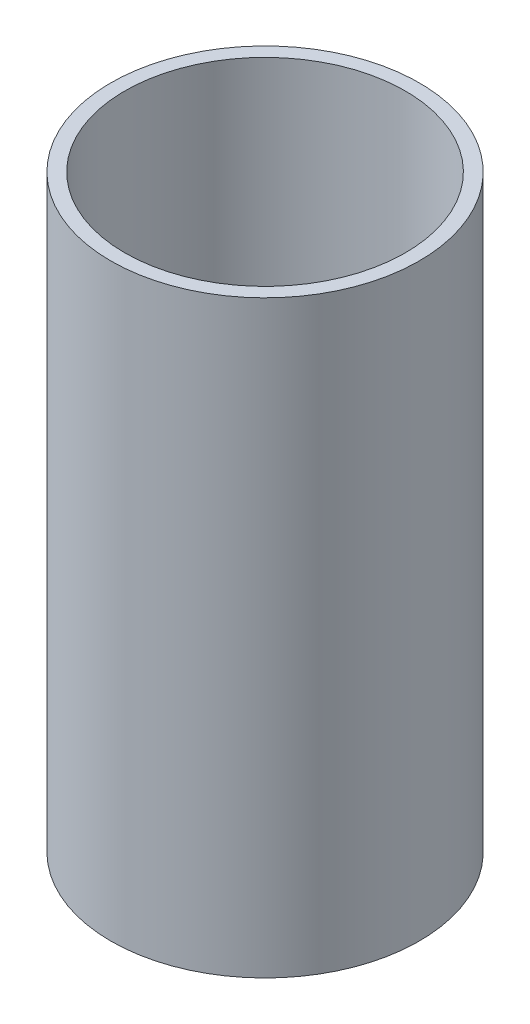
from build123d import *

# Parameters (mm, degrees)
SKETCH1_R           = 41.9
SKETCH1_R_2         = 38.1
BOSS_EXTRUDE1_DEPTH = 160


with BuildPart() as part:
    # Sketch1 → Boss-Extrude1 (new body)
    with BuildSketch(Plane(origin=(0, 0, 0), x_dir=(1, 0, 0), z_dir=(0, 1, 0))):
        Circle(SKETCH1_R)
        Circle(SKETCH1_R_2, mode=Mode.SUBTRACT)
    extrude(amount=BOSS_EXTRUDE1_DEPTH)


solid = part.part
